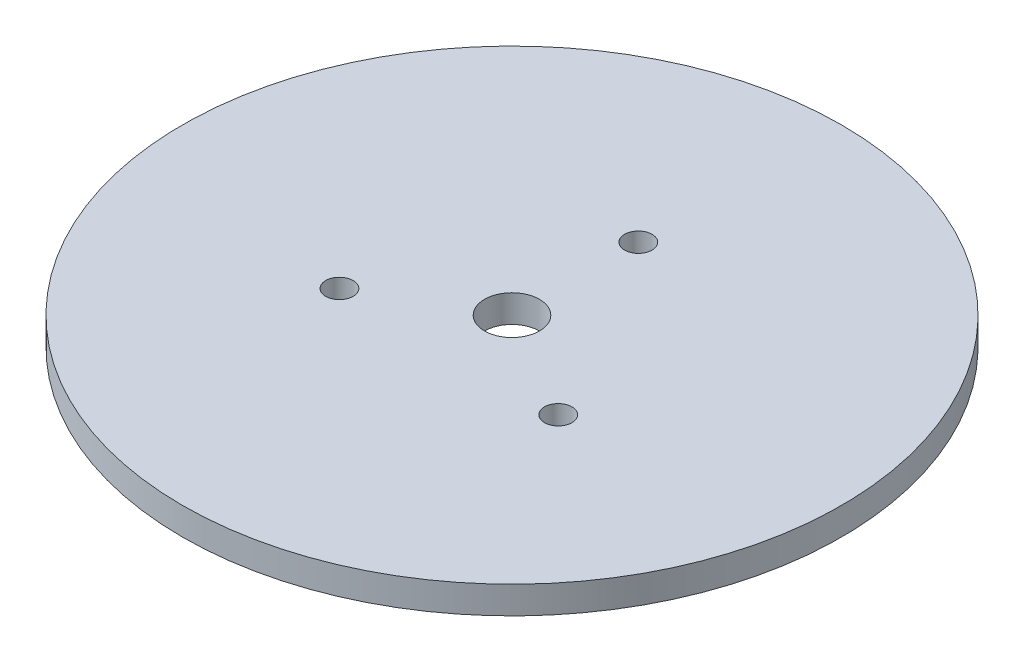
from build123d import *

# Parameters (mm, degrees)
SKETCH1_R           = 60
SKETCH1_R_2         = 5
SKETCH1_R_3         = 2.5
BOSS_EXTRUDE1_DEPTH = 5


with BuildPart() as part:
    # Sketch1 → Boss-Extrude1 (new body)
    with BuildSketch(Plane(origin=(0, 0, 0), x_dir=(1, 0, 0), z_dir=(0, 1, 0))):
        Circle(SKETCH1_R)
        Circle(SKETCH1_R_2, mode=Mode.SUBTRACT)
        with Locations((0, 23)):
            Circle(SKETCH1_R_3, mode=Mode.SUBTRACT)
        with Locations((19.918584287, -11.5)):
            Circle(SKETCH1_R_3, mode=Mode.SUBTRACT)
        with Locations((-19.918584287, -11.5)):
            Circle(SKETCH1_R_3, mode=Mode.SUBTRACT)
    extrude(amount=BOSS_EXTRUDE1_DEPTH)


solid = part.part
